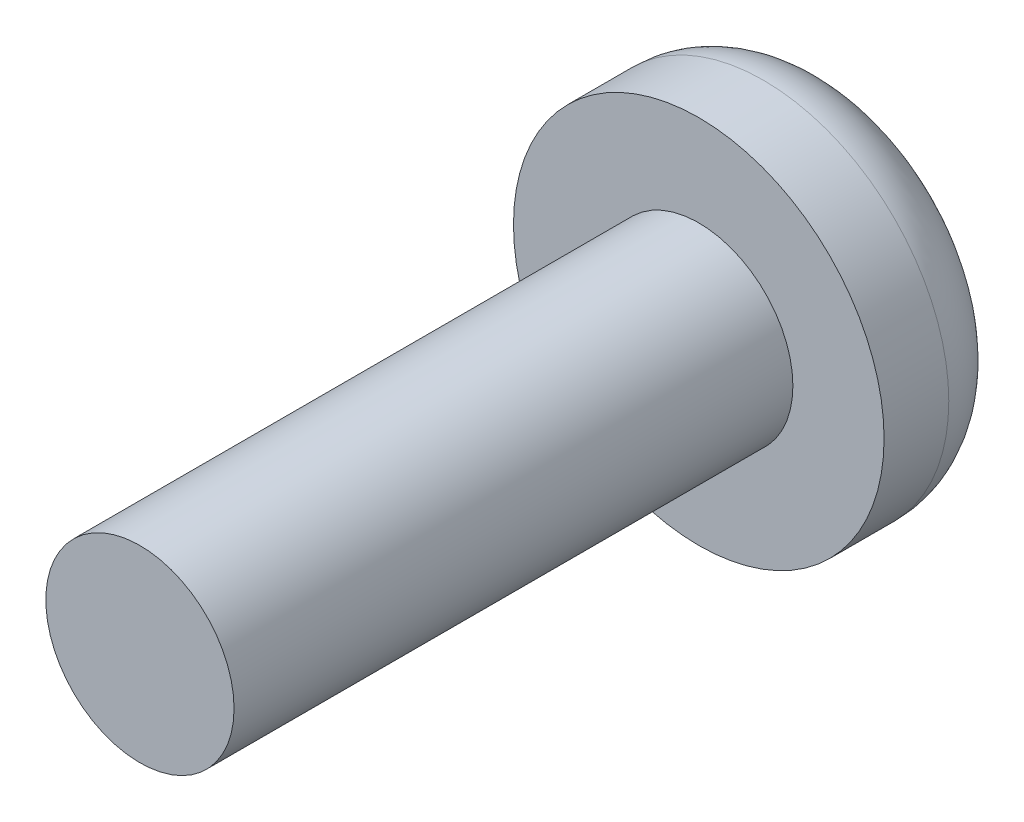
from build123d import *

# Parameters (mm, degrees)
SKETCH1_R         = 4.0005
EXTRUDE1_DEPTH    = 2.921
FILLET1_R         = 1.524
SKETCH2_R         = 2.032
EXTRUDE2_DEPTH    = 12.065
SKETCH3_W         = 4.91456988
SKETCH3_H         = 0.615801824
EXTRUDE3_DEPTH    = 1.016
CIRPATTERN1_COUNT = 2
CIRPATTERN1_ANGLE = 90


with BuildPart() as part:
    # Sketch1 → Extrude1 (new body)
    with BuildSketch(Plane.XY):
        Circle(SKETCH1_R)
    extrude(amount=EXTRUDE1_DEPTH)

    # Fillet1
    fillet1_edges = [part.edges().sort_by_distance(p)[0] for p in [
        (-4.0005, 0, 0),
    ]]
    fillet(fillet1_edges, radius=FILLET1_R)

    # Sketch2 → Extrude2 (add)
    with BuildSketch(Plane.XY.offset(2.921)):
        Circle(SKETCH2_R)
    extrude(amount=EXTRUDE2_DEPTH)

    # Sketch3 → Extrude3 (cut)
    with BuildSketch(Plane(origin=(0, 0, 0), x_dir=(-1, 0, 0), z_dir=(0, 0, -1))):
        Rectangle(SKETCH3_W, SKETCH3_H)
    extrude3 = extrude(amount=-EXTRUDE3_DEPTH, mode=Mode.SUBTRACT)

    # CirPattern1: Extrude3 ×2 about axis
    cirpattern1_axis = Axis((0, 0, 0), (0, 0, -1))
    for i in range(1, CIRPATTERN1_COUNT):
        add(extrude3.rotate(cirpattern1_axis, i * CIRPATTERN1_ANGLE / (CIRPATTERN1_COUNT - 1)), mode=Mode.SUBTRACT)


solid = part.part
